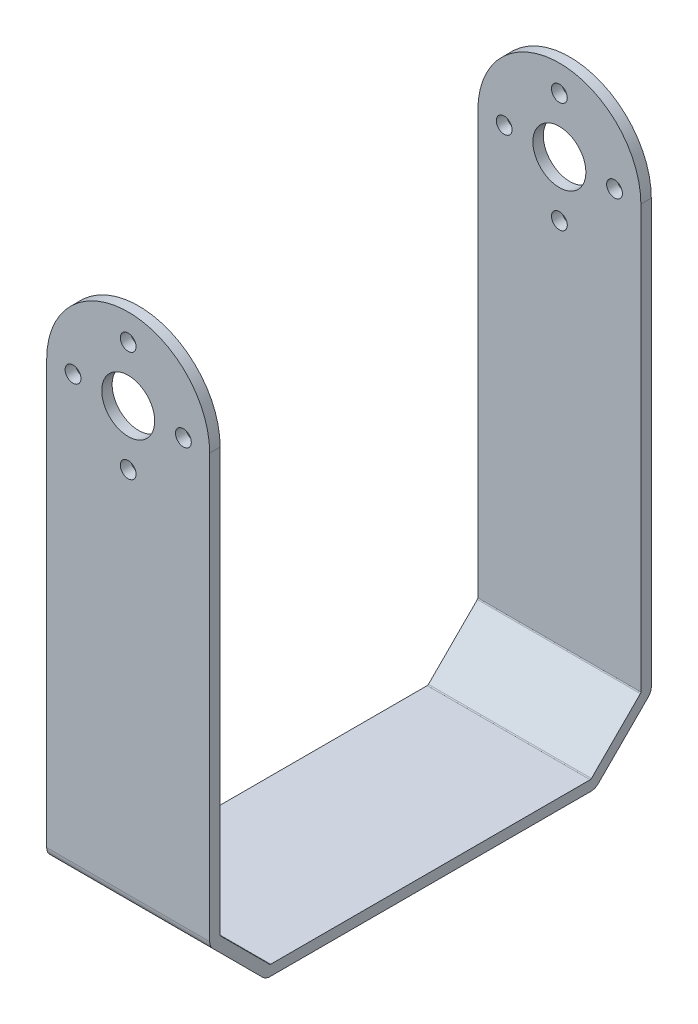
from build123d import *

# Parameters (mm, degrees)
SKETCH2_W         = 66.675
SKETCH2_H         = 85.3186
EXTRUDE1_DEPTH    = 24.6126
SKETCH3_OUTSIDE_W = 90.883
SKETCH3_OUTSIDE_H = 109.527
EXTRUDE2_DEPTH    = 24.6126
SKETCH4_OUTSIDE_W = 48.821
SKETCH4_OUTSIDE_H = 109.527
EXTRUDE3_DEPTH    = 67.675
FILLET1_R         = 1.5875
FILLET2_R         = 0.254
SKETCH5_R         = 4.0005
SKETCH5_R_2       = 1.1938
EXTRUDE4_DEPTH    = 67.675


with BuildPart() as part:
    # Sketch2 → Extrude1 (new body)
    with BuildSketch(Plane(origin=(0, 0, 0), x_dir=(0, 0, -1), z_dir=(1, 0, 0))):
        with Locations((33.3375, 42.6593)):
            Rectangle(SKETCH2_W, SKETCH2_H)
    extrude(amount=EXTRUDE1_DEPTH)

    # Sketch3 outside → Extrude2 (cut)
    with BuildSketch(Plane(origin=(24.6126, 0, 0), x_dir=(0, 0, -1), z_dir=(1, 0, 0))):
        with Locations((33.3375, 42.6595)):
            Rectangle(SKETCH3_OUTSIDE_W, SKETCH3_OUTSIDE_H)
        Polygon((1.5748, 85.3186), (1.5748, 9.1186), (9.1186, 1.5748), (57.5564, 1.5748), (65.1002, 9.1186), (65.1002, 85.3186), (66.675, 85.3186), (66.675, 8.466296482), (58.208703518, 0), (8.466296482, 0), (0, 8.466296482), (0, 85.3186), align=None, mode=Mode.SUBTRACT)
    extrude(amount=-EXTRUDE2_DEPTH, mode=Mode.SUBTRACT)

    # Sketch4 outside → Extrude3 (cut, through all)
    with BuildSketch(Plane.XY):
        with Locations((12.3065, 42.6595)):
            Rectangle(SKETCH4_OUTSIDE_W, SKETCH4_OUTSIDE_H)
        with BuildLine():
            Line((0, 73.0123), (0, 0))
            Line((0, 0), (24.6126, 0))
            Line((24.6126, 0), (24.6126, 73.0123))
            ThreePointArc((24.6126, 73.0123), (12.3063, 85.3186), (0, 73.0123))
        make_face(mode=Mode.SUBTRACT)
    extrude(amount=-EXTRUDE3_DEPTH, mode=Mode.SUBTRACT)

    # Fillet1
    fillet1_edges = [part.edges().sort_by_distance(p)[0] for p in [
        (12.3063, 8.466296482, -66.675),
        (12.3063, 0, -58.208703518),
        (12.3063, 0, -8.466296482),
        (12.3063, 8.466296482, 0),
    ]]
    fillet(fillet1_edges, radius=FILLET1_R)

    # Fillet2
    fillet2_edges = [part.edges().sort_by_distance(p)[0] for p in [
        (12.3063, 9.1186, -1.5748),
        (12.3063, 1.5748, -9.1186),
        (12.3063, 1.5748, -57.5564),
        (12.3063, 9.1186, -65.1002),
    ]]
    fillet(fillet2_edges, radius=FILLET2_R)

    # Sketch5 → Extrude4 (cut, through all)
    with BuildSketch(Plane.XY):
        with Locations((12.3063, 73.025)):
            Circle(SKETCH5_R)
        with Locations((12.3063, 81.3562)):
            Circle(SKETCH5_R_2)
        with Locations((3.9751, 73.025)):
            Circle(SKETCH5_R_2)
        with Locations((12.3063, 64.6938)):
            Circle(SKETCH5_R_2)
        with Locations((20.6375, 73.025)):
            Circle(SKETCH5_R_2)
    extrude(amount=-EXTRUDE4_DEPTH, mode=Mode.SUBTRACT)


solid = part.part
